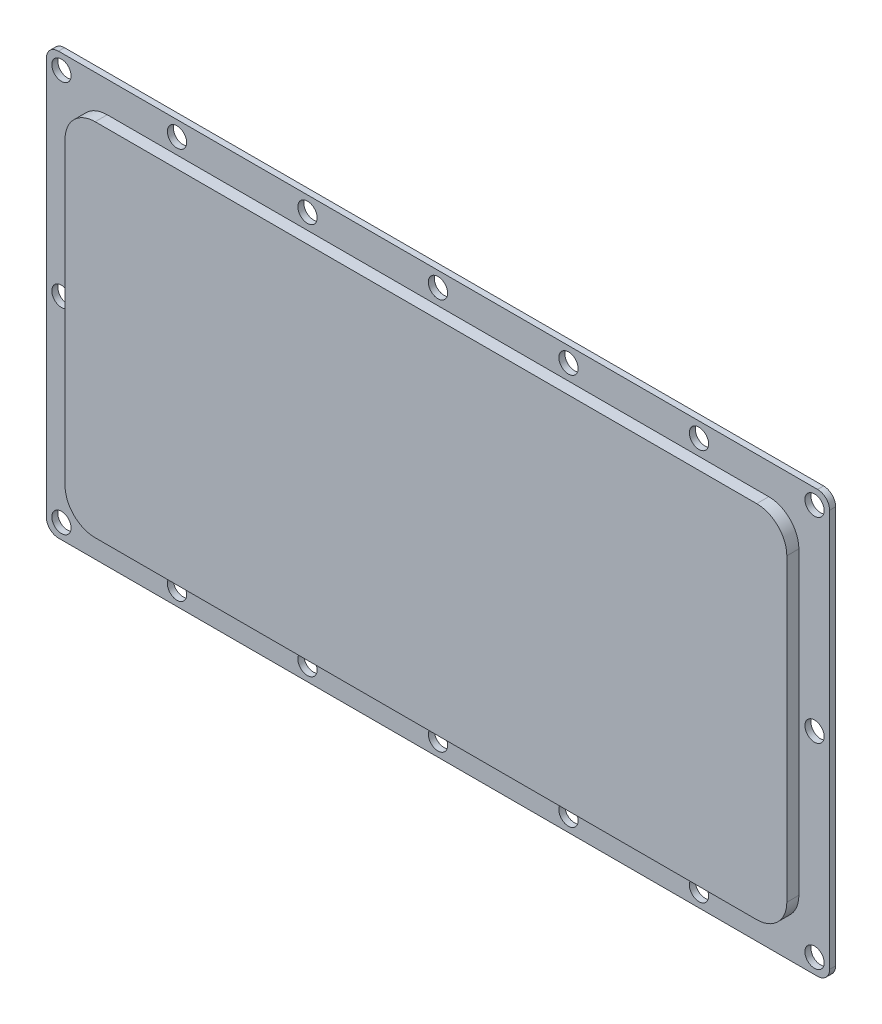
from build123d import *

# Parameters (mm, degrees)
BOSS_EXTRU_1_DEPTH      = 1
BOSS_EXTRU_2_DEPTH      = 2
ENL_V_MAT_EXTRU_1_REACH = 5
ESQUISSE3_R             = 1.6


with BuildPart() as part:
    # Esquisse1 → Boss.-Extru.1 (new body)
    with BuildSketch(Plane.XY):
        with BuildLine():
            Line((2, 0), (128, 0))
            ThreePointArc((128, 0), (129.414213562, 0.585786438), (130, 2))
            Line((130, 2), (130, 68))
            ThreePointArc((130, 68), (129.414213562, 69.414213562), (128, 70))
            Line((128, 70), (2, 70))
            ThreePointArc((2, 70), (0.585786438, 69.414213562), (0, 68))
            Line((0, 68), (0, 2))
            ThreePointArc((0, 2), (0.585786438, 0.585786438), (2, 0))
        make_face()
    extrude(amount=BOSS_EXTRU_1_DEPTH)

    # Esquisse2 → Boss.-Extru.2 (add)
    with BuildSketch(Plane.XY.offset(1)):
        with BuildLine():
            Line((10.1, 64.9), (119.9, 64.9))
            ThreePointArc((119.9, 64.9), (123.435533906, 63.435533906), (124.9, 59.9))
            Line((124.9, 59.9), (124.9, 10.1))
            ThreePointArc((124.9, 10.1), (123.435533906, 6.564466094), (119.9, 5.1))
            Line((119.9, 5.1), (10.1, 5.1))
            ThreePointArc((10.1, 5.1), (6.564466094, 6.564466094), (5.1, 10.1))
            Line((5.1, 10.1), (5.1, 59.9))
            ThreePointArc((5.1, 59.9), (6.564466094, 63.435533906), (10.1, 64.9))
        make_face()
    extrude(amount=BOSS_EXTRU_2_DEPTH)

    # Esquisse3 → Enlèv. mat.-Extru.1 (cut, up to next)
    with BuildSketch(Plane(origin=(0, 0, 0), x_dir=(-1, 0, 0), z_dir=(0, 0, -1)), mode=Mode.PRIVATE) as enl_v_mat_extru_1_sk1:
        with Locations((-65, 67.5)):
            Circle(ESQUISSE3_R)
    enl_v_mat_extru_1_tool1 = extrude(enl_v_mat_extru_1_sk1.sketch, amount=-ENL_V_MAT_EXTRU_1_REACH, mode=Mode.PRIVATE) & part.part
    add(enl_v_mat_extru_1_tool1.solids().sort_by_distance((65, 67.5, 0))[0], mode=Mode.SUBTRACT)
    # Esquisse3 → Enlèv. mat.-Extru.1 (cut, up to next)
    with BuildSketch(Plane(origin=(0, 0, 0), x_dir=(-1, 0, 0), z_dir=(0, 0, -1)), mode=Mode.PRIVATE) as enl_v_mat_extru_1_sk2:
        with Locations((-43.34, 67.5)):
            Circle(ESQUISSE3_R)
    enl_v_mat_extru_1_tool2 = extrude(enl_v_mat_extru_1_sk2.sketch, amount=-ENL_V_MAT_EXTRU_1_REACH, mode=Mode.PRIVATE) & part.part
    add(enl_v_mat_extru_1_tool2.solids().sort_by_distance((43.34, 67.5, 0))[0], mode=Mode.SUBTRACT)
    # Esquisse3 → Enlèv. mat.-Extru.1 (cut, up to next)
    with BuildSketch(Plane(origin=(0, 0, 0), x_dir=(-1, 0, 0), z_dir=(0, 0, -1)), mode=Mode.PRIVATE) as enl_v_mat_extru_1_sk3:
        with Locations((-21.68, 67.5)):
            Circle(ESQUISSE3_R)
    enl_v_mat_extru_1_tool3 = extrude(enl_v_mat_extru_1_sk3.sketch, amount=-ENL_V_MAT_EXTRU_1_REACH, mode=Mode.PRIVATE) & part.part
    add(enl_v_mat_extru_1_tool3.solids().sort_by_distance((21.68, 67.5, 0))[0], mode=Mode.SUBTRACT)
    # Esquisse3 → Enlèv. mat.-Extru.1 (cut, up to next)
    with BuildSketch(Plane(origin=(0, 0, 0), x_dir=(-1, 0, 0), z_dir=(0, 0, -1)), mode=Mode.PRIVATE) as enl_v_mat_extru_1_sk4:
        with Locations((-2.5, 67.5)):
            Circle(ESQUISSE3_R)
    enl_v_mat_extru_1_tool4 = extrude(enl_v_mat_extru_1_sk4.sketch, amount=-ENL_V_MAT_EXTRU_1_REACH, mode=Mode.PRIVATE) & part.part
    add(enl_v_mat_extru_1_tool4.solids().sort_by_distance((2.5, 67.5, 0))[0], mode=Mode.SUBTRACT)
    # Esquisse3 → Enlèv. mat.-Extru.1 (cut, up to next)
    with BuildSketch(Plane(origin=(0, 0, 0), x_dir=(-1, 0, 0), z_dir=(0, 0, -1)), mode=Mode.PRIVATE) as enl_v_mat_extru_1_sk5:
        with Locations((-2.5, 2.5)):
            Circle(ESQUISSE3_R)
    enl_v_mat_extru_1_tool5 = extrude(enl_v_mat_extru_1_sk5.sketch, amount=-ENL_V_MAT_EXTRU_1_REACH, mode=Mode.PRIVATE) & part.part
    add(enl_v_mat_extru_1_tool5.solids().sort_by_distance((2.5, 2.5, 0))[0], mode=Mode.SUBTRACT)
    # Esquisse3 → Enlèv. mat.-Extru.1 (cut, up to next)
    with BuildSketch(Plane(origin=(0, 0, 0), x_dir=(-1, 0, 0), z_dir=(0, 0, -1)), mode=Mode.PRIVATE) as enl_v_mat_extru_1_sk6:
        with Locations((-21.68, 2.5)):
            Circle(ESQUISSE3_R)
    enl_v_mat_extru_1_tool6 = extrude(enl_v_mat_extru_1_sk6.sketch, amount=-ENL_V_MAT_EXTRU_1_REACH, mode=Mode.PRIVATE) & part.part
    add(enl_v_mat_extru_1_tool6.solids().sort_by_distance((21.68, 2.5, 0))[0], mode=Mode.SUBTRACT)
    # Esquisse3 → Enlèv. mat.-Extru.1 (cut, up to next)
    with BuildSketch(Plane(origin=(0, 0, 0), x_dir=(-1, 0, 0), z_dir=(0, 0, -1)), mode=Mode.PRIVATE) as enl_v_mat_extru_1_sk7:
        with Locations((-43.34, 2.5)):
            Circle(ESQUISSE3_R)
    enl_v_mat_extru_1_tool7 = extrude(enl_v_mat_extru_1_sk7.sketch, amount=-ENL_V_MAT_EXTRU_1_REACH, mode=Mode.PRIVATE) & part.part
    add(enl_v_mat_extru_1_tool7.solids().sort_by_distance((43.34, 2.5, 0))[0], mode=Mode.SUBTRACT)
    # Esquisse3 → Enlèv. mat.-Extru.1 (cut, up to next)
    with BuildSketch(Plane(origin=(0, 0, 0), x_dir=(-1, 0, 0), z_dir=(0, 0, -1)), mode=Mode.PRIVATE) as enl_v_mat_extru_1_sk8:
        with Locations((-65, 2.5)):
            Circle(ESQUISSE3_R)
    enl_v_mat_extru_1_tool8 = extrude(enl_v_mat_extru_1_sk8.sketch, amount=-ENL_V_MAT_EXTRU_1_REACH, mode=Mode.PRIVATE) & part.part
    add(enl_v_mat_extru_1_tool8.solids().sort_by_distance((65, 2.5, 0))[0], mode=Mode.SUBTRACT)
    # Esquisse3 → Enlèv. mat.-Extru.1 (cut, up to next)
    with BuildSketch(Plane(origin=(0, 0, 0), x_dir=(-1, 0, 0), z_dir=(0, 0, -1)), mode=Mode.PRIVATE) as enl_v_mat_extru_1_sk9:
        with Locations((-86.66, 2.5)):
            Circle(ESQUISSE3_R)
    enl_v_mat_extru_1_tool9 = extrude(enl_v_mat_extru_1_sk9.sketch, amount=-ENL_V_MAT_EXTRU_1_REACH, mode=Mode.PRIVATE) & part.part
    add(enl_v_mat_extru_1_tool9.solids().sort_by_distance((86.66, 2.5, 0))[0], mode=Mode.SUBTRACT)
    # Esquisse3 → Enlèv. mat.-Extru.1 (cut, up to next)
    with BuildSketch(Plane(origin=(0, 0, 0), x_dir=(-1, 0, 0), z_dir=(0, 0, -1)), mode=Mode.PRIVATE) as enl_v_mat_extru_1_sk10:
        with Locations((-108.32, 2.5)):
            Circle(ESQUISSE3_R)
    enl_v_mat_extru_1_tool10 = extrude(enl_v_mat_extru_1_sk10.sketch, amount=-ENL_V_MAT_EXTRU_1_REACH, mode=Mode.PRIVATE) & part.part
    add(enl_v_mat_extru_1_tool10.solids().sort_by_distance((108.32, 2.5, 0))[0], mode=Mode.SUBTRACT)
    # Esquisse3 → Enlèv. mat.-Extru.1 (cut, up to next)
    with BuildSketch(Plane(origin=(0, 0, 0), x_dir=(-1, 0, 0), z_dir=(0, 0, -1)), mode=Mode.PRIVATE) as enl_v_mat_extru_1_sk11:
        with Locations((-127.5, 2.5)):
            Circle(ESQUISSE3_R)
    enl_v_mat_extru_1_tool11 = extrude(enl_v_mat_extru_1_sk11.sketch, amount=-ENL_V_MAT_EXTRU_1_REACH, mode=Mode.PRIVATE) & part.part
    add(enl_v_mat_extru_1_tool11.solids().sort_by_distance((127.5, 2.5, 0))[0], mode=Mode.SUBTRACT)
    # Esquisse3 → Enlèv. mat.-Extru.1 (cut, up to next)
    with BuildSketch(Plane(origin=(0, 0, 0), x_dir=(-1, 0, 0), z_dir=(0, 0, -1)), mode=Mode.PRIVATE) as enl_v_mat_extru_1_sk12:
        with Locations((-127.5, 67.5)):
            Circle(ESQUISSE3_R)
    enl_v_mat_extru_1_tool12 = extrude(enl_v_mat_extru_1_sk12.sketch, amount=-ENL_V_MAT_EXTRU_1_REACH, mode=Mode.PRIVATE) & part.part
    add(enl_v_mat_extru_1_tool12.solids().sort_by_distance((127.5, 67.5, 0))[0], mode=Mode.SUBTRACT)
    # Esquisse3 → Enlèv. mat.-Extru.1 (cut, up to next)
    with BuildSketch(Plane(origin=(0, 0, 0), x_dir=(-1, 0, 0), z_dir=(0, 0, -1)), mode=Mode.PRIVATE) as enl_v_mat_extru_1_sk13:
        with Locations((-108.32, 67.5)):
            Circle(ESQUISSE3_R)
    enl_v_mat_extru_1_tool13 = extrude(enl_v_mat_extru_1_sk13.sketch, amount=-ENL_V_MAT_EXTRU_1_REACH, mode=Mode.PRIVATE) & part.part
    add(enl_v_mat_extru_1_tool13.solids().sort_by_distance((108.32, 67.5, 0))[0], mode=Mode.SUBTRACT)
    # Esquisse3 → Enlèv. mat.-Extru.1 (cut, up to next)
    with BuildSketch(Plane(origin=(0, 0, 0), x_dir=(-1, 0, 0), z_dir=(0, 0, -1)), mode=Mode.PRIVATE) as enl_v_mat_extru_1_sk14:
        with Locations((-86.66, 67.5)):
            Circle(ESQUISSE3_R)
    enl_v_mat_extru_1_tool14 = extrude(enl_v_mat_extru_1_sk14.sketch, amount=-ENL_V_MAT_EXTRU_1_REACH, mode=Mode.PRIVATE) & part.part
    add(enl_v_mat_extru_1_tool14.solids().sort_by_distance((86.66, 67.5, 0))[0], mode=Mode.SUBTRACT)
    # Esquisse3 → Enlèv. mat.-Extru.1 (cut, up to next)
    with BuildSketch(Plane(origin=(0, 0, 0), x_dir=(-1, 0, 0), z_dir=(0, 0, -1)), mode=Mode.PRIVATE) as enl_v_mat_extru_1_sk15:
        with Locations((-2.5, 35)):
            Circle(ESQUISSE3_R)
    enl_v_mat_extru_1_tool15 = extrude(enl_v_mat_extru_1_sk15.sketch, amount=-ENL_V_MAT_EXTRU_1_REACH, mode=Mode.PRIVATE) & part.part
    add(enl_v_mat_extru_1_tool15.solids().sort_by_distance((2.5, 35, 0))[0], mode=Mode.SUBTRACT)
    # Esquisse3 → Enlèv. mat.-Extru.1 (cut, up to next)
    with BuildSketch(Plane(origin=(0, 0, 0), x_dir=(-1, 0, 0), z_dir=(0, 0, -1)), mode=Mode.PRIVATE) as enl_v_mat_extru_1_sk16:
        with Locations((-127.5, 35)):
            Circle(ESQUISSE3_R)
    enl_v_mat_extru_1_tool16 = extrude(enl_v_mat_extru_1_sk16.sketch, amount=-ENL_V_MAT_EXTRU_1_REACH, mode=Mode.PRIVATE) & part.part
    add(enl_v_mat_extru_1_tool16.solids().sort_by_distance((127.5, 35, 0))[0], mode=Mode.SUBTRACT)


solid = part.part
